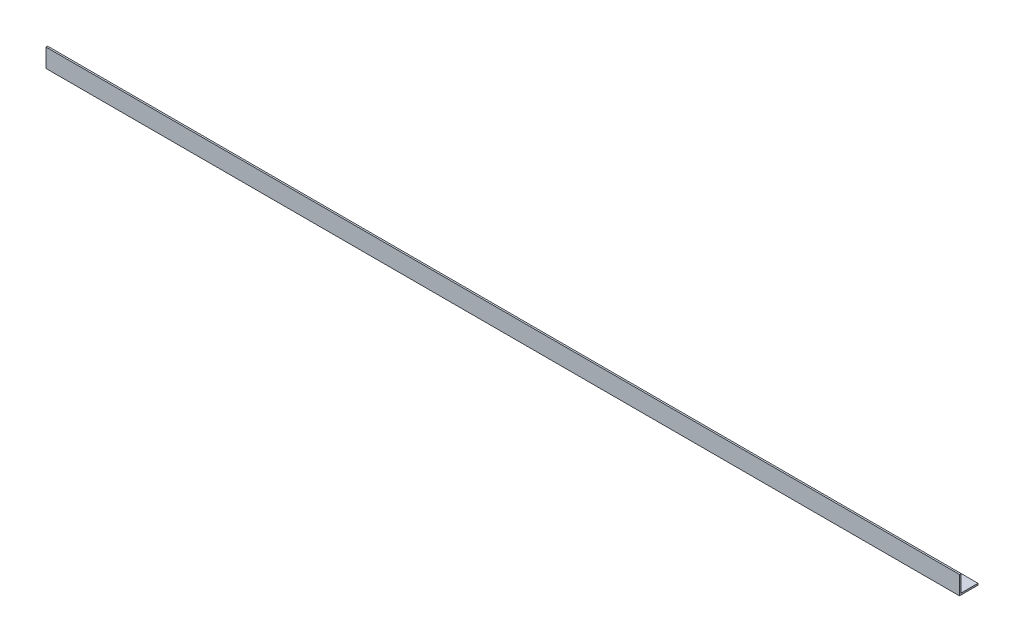
from build123d import *

# Parameters (mm, degrees)
EXTRUDE_1_DEPTH = 1660


with BuildPart() as part:
    # Эскиз1 → Вытянуть-Тонкостенный1 (new body)
    with BuildSketch(Plane(origin=(0, 0, 0), x_dir=(0, 0, -1), z_dir=(1, 0, 0))):
        Polygon((0, 33.7), (0, 0), (33.7, 0), (33.7, 3), (3, 3), (3, 33.7), align=None)
    extrude(amount=EXTRUDE_1_DEPTH)


solid = part.part
